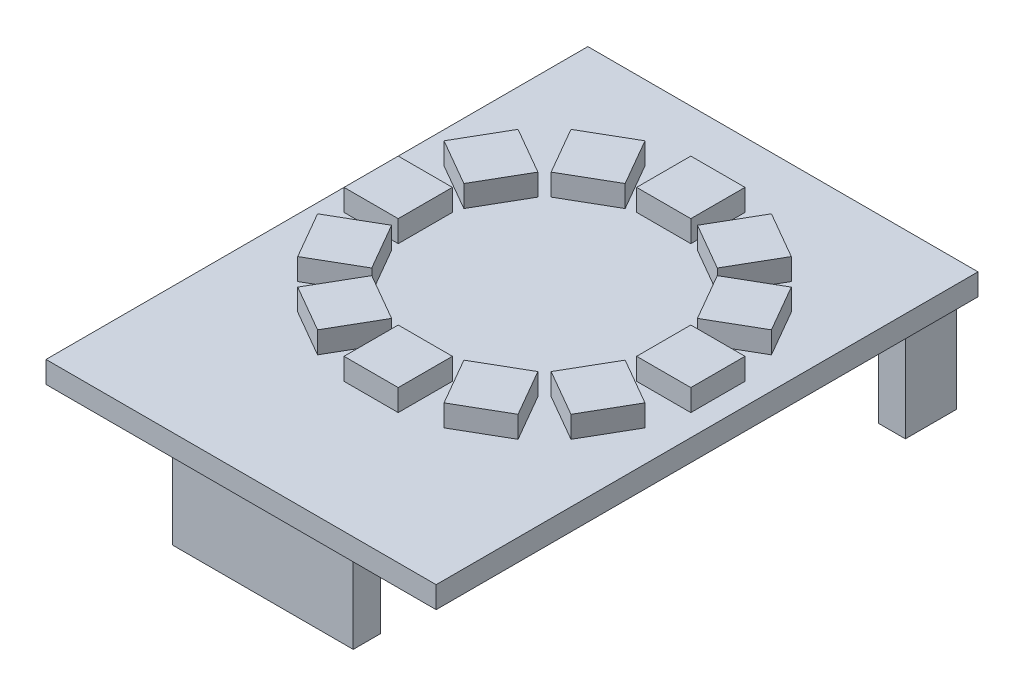
from build123d import *

# Parameters (mm, degrees)
SKETCH1_W           = 36
SKETCH1_H           = 50
BOSS_EXTRUDE1_DEPTH = 2
SKETCH2_W           = 5
SKETCH2_H           = 5
BOSS_EXTRUDE2_DEPTH = 2
CIRPATTERN1_COUNT   = 12
SKETCH3_W           = 16.7
SKETCH3_H           = 2.5
SKETCH3_W_2         = 2.5
SKETCH3_H_2         = 4.7
BOSS_EXTRUDE3_DEPTH = 9


with BuildPart() as part:
    # Sketch1 → Boss-Extrude1 (new body)
    with BuildSketch(Plane(origin=(0, 0, 0), x_dir=(1, 0, 0), z_dir=(0, 1, 0))):
        with Locations((0, -3)):
            Rectangle(SKETCH1_W, SKETCH1_H)
    extrude(amount=BOSS_EXTRUDE1_DEPTH)

    # Sketch2 → Boss-Extrude2 (add)
    with BuildSketch(Plane(origin=(0, 2, 0), x_dir=(1, 0, 0), z_dir=(0, 1, 0))):
        with Locations((0, 13.5)):
            Rectangle(SKETCH2_W, SKETCH2_H)
    boss_extrude2 = extrude(amount=BOSS_EXTRUDE2_DEPTH)

    # CirPattern1: Boss-Extrude2 ×12 about axis
    cirpattern1_axis = Axis((0, 0, 0), (0, 1, 0))
    for i in range(1, CIRPATTERN1_COUNT):
        add(boss_extrude2.rotate(cirpattern1_axis, i * 360 / CIRPATTERN1_COUNT))

    # Sketch3 → Boss-Extrude3 (add)
    with BuildSketch(Plane.XZ):
        with Locations((0, 24.75)):
            Rectangle(SKETCH3_W, SKETCH3_H)
        with Locations((-15.75, -18.65)):
            Rectangle(SKETCH3_W_2, SKETCH3_H_2)
        with Locations((15.75, -18.65)):
            Rectangle(SKETCH3_W_2, SKETCH3_H_2)
    extrude(amount=BOSS_EXTRUDE3_DEPTH)


solid = part.part
